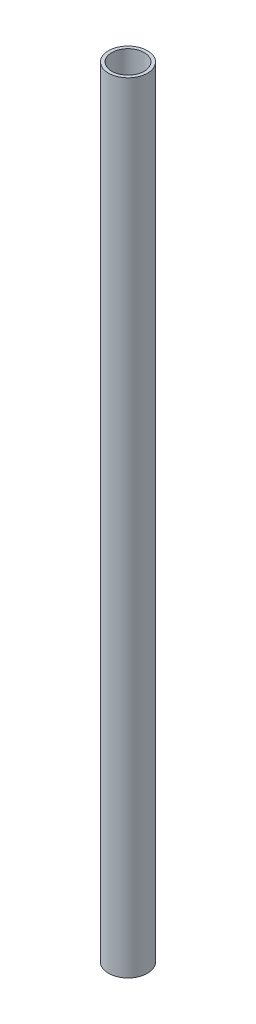
from build123d import *

# Parameters (mm, degrees)
SKETCH1_R           = 30.48
SKETCH1_R_2         = 25.4
BOSS_EXTRUDE1_DEPTH = 609.6


with BuildPart() as part:
    # Sketch1 → Boss-Extrude1 (new body, symmetric)
    with BuildSketch(Plane(origin=(0, 0, 0), x_dir=(1, 0, 0), z_dir=(0, 1, 0))):
        Circle(SKETCH1_R)
        Circle(SKETCH1_R_2, mode=Mode.SUBTRACT)
    extrude(amount=BOSS_EXTRUDE1_DEPTH, both=True)


solid = part.part
